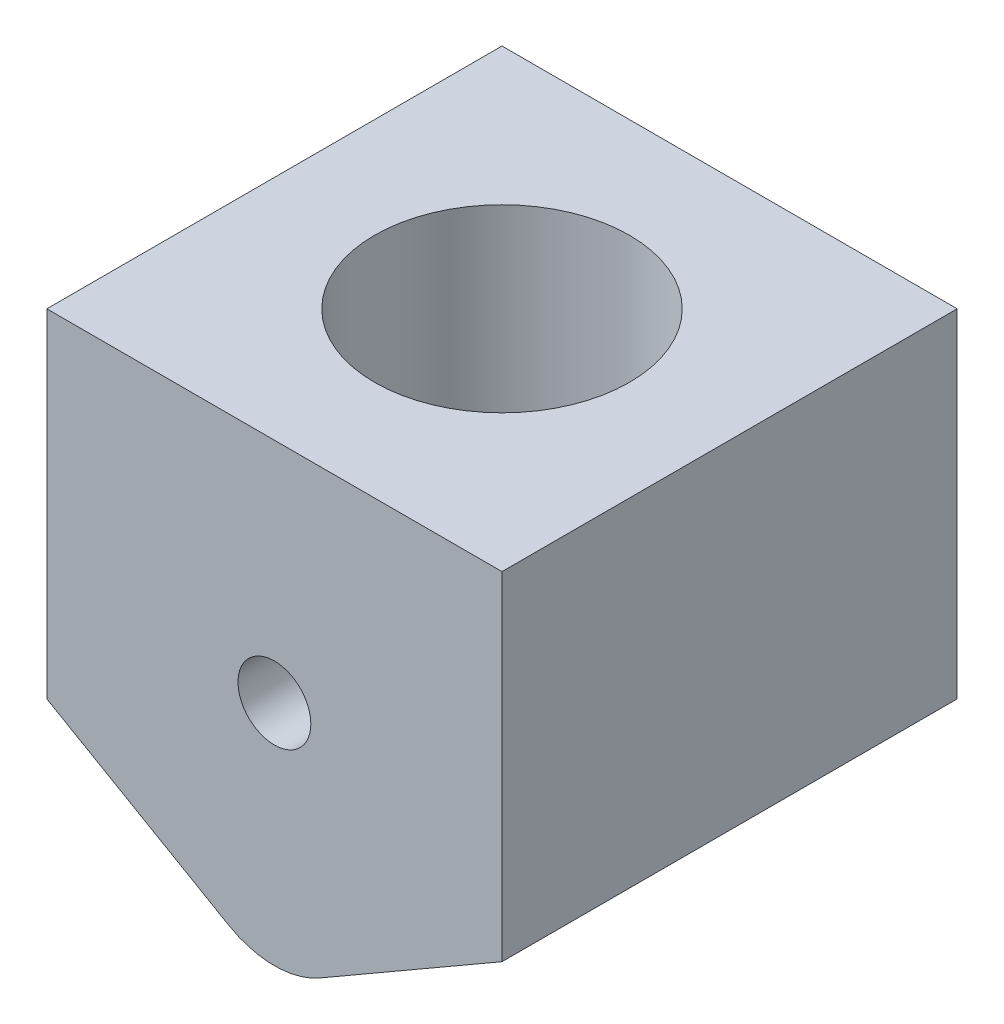
from build123d import *

# Parameters (mm, degrees)
BOSS_EXTRUDE1_DEPTH = 25
SKETCH2_R           = 14
CUT_EXTRUDE1_DEPTH  = 29
CUT_EXTRUDE2_REACH  = 52
SKETCH3_R           = 4


with BuildPart() as part:
    # Sketch1 → Boss-Extrude1 (new body, symmetric)
    with BuildSketch(Plane.XY):
        with BuildLine():
            Line((-25, 0), (25, 0))
            Line((25, 0), (25, -37.113248654))
            Line((25, -37.113248654), (5, -48.660254038))
            ThreePointArc((5, -48.660254038), (0, -50), (-5, -48.660254038))
            Line((-5, -48.660254038), (-25, -37.113248654))
            Line((-25, -37.113248654), (-25, 0))
        make_face()
    extrude(amount=BOSS_EXTRUDE1_DEPTH, both=True)

    # Sketch2 → Cut-Extrude1 (cut)
    with BuildSketch(Plane(origin=(0, 0, 0), x_dir=(1, 0, 0), z_dir=(0, 1, 0))):
        Circle(SKETCH2_R)
    extrude(amount=-CUT_EXTRUDE1_DEPTH, mode=Mode.SUBTRACT)

    # Sketch3 → Cut-Extrude2 (cut, up to next)
    with BuildSketch(Plane.XY.offset(25), mode=Mode.PRIVATE) as cut_extrude2_sk1:
        with Locations((0, -25)):
            Circle(SKETCH3_R)
    cut_extrude2_tool1 = extrude(cut_extrude2_sk1.sketch, amount=-CUT_EXTRUDE2_REACH, mode=Mode.PRIVATE) & part.part
    add(cut_extrude2_tool1.solids().sort_by_distance((0, -25, 25))[0], mode=Mode.SUBTRACT)


solid = part.part
